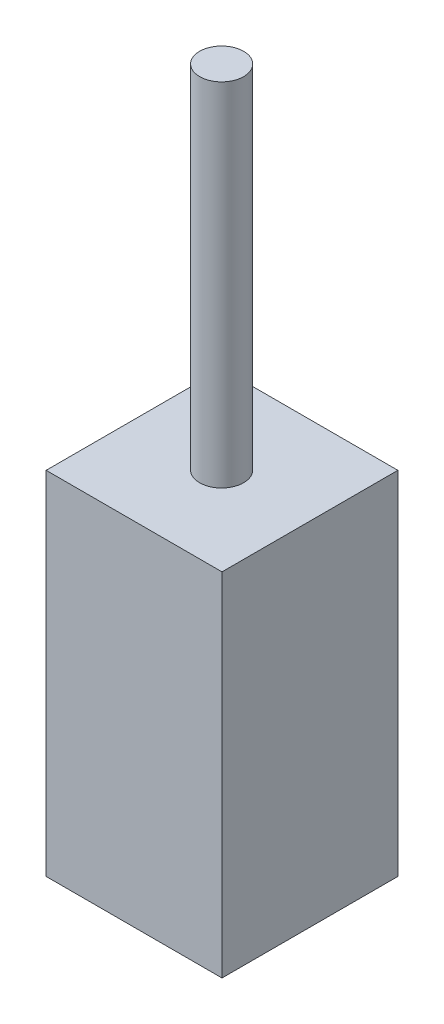
from build123d import *

# Parameters (mm, degrees)
SKETCH1_W           = 25.4
SKETCH1_H           = 25.4
BOSS_EXTRUDE1_DEPTH = 50.8
SKETCH2_R           = 3.175
BOSS_EXTRUDE2_DEPTH = 50.8
CUT_EXTRUDE1_DEPTH  = 1.27


with BuildPart() as part:
    # Sketch1 → Boss-Extrude1 (new body)
    with BuildSketch(Plane(origin=(0, 0, 0), x_dir=(1, 0, 0), z_dir=(0, 1, 0))):
        with Locations((12.7, 12.7)):
            Rectangle(SKETCH1_W, SKETCH1_H)
    extrude(amount=BOSS_EXTRUDE1_DEPTH)

    # Sketch2 → Boss-Extrude2 (add)
    with BuildSketch(Plane(origin=(0, 50.8, 0), x_dir=(1, 0, 0), z_dir=(0, 1, 0))):
        with Locations((12.648058093, 12.7)):
            Circle(SKETCH2_R)
    extrude(amount=BOSS_EXTRUDE2_DEPTH)

    # Sketch3 → Cut-Extrude1 (cut)
    with BuildSketch(Plane.ZY):
        Polygon((-20.429638912, 24.416659376), (-20.010503295, 27.591659376), (-19.969798167, 27.591659376), (-18.658965835, 24.986531171), (-17.351313592, 27.591659376), (-17.309972446, 27.591659376), (-16.888292758, 24.416659376), (-17.174500691, 24.416659376), (-17.478517117, 26.701234697), (-18.624620883, 24.416659376), (-18.688858664, 24.416659376), (-19.839414553, 26.706322838), (-20.142794962, 24.416659376), align=None)
        Polygon((-16.237010707, 27.591659376), (-14.445985066, 27.591659376), (-14.445985066, 27.26601835), (-15.95207481, 27.26601835), (-15.95207481, 26.289095273), (-14.445985066, 26.289095273), (-14.445985066, 25.963454248), (-15.95207481, 25.963454248), (-15.95207481, 24.742300402), (-14.445985066, 24.742300402), (-14.445985066, 24.416659376), (-16.237010707, 24.416659376), align=None)
        with BuildLine():
            add(Edge.make_bspline(
                [(-12.390376092, 27.673069632), (-12.331585881, 27.671580576), (-12.216117058, 27.668655947), (-12.046413401, 27.646268474), (-11.884402136, 27.607537656), (-11.72876351, 27.555954808), (-11.581359167, 27.487144044), (-11.4410796, 27.403972516), (-11.308258579, 27.305568872), (-11.184686325, 27.192693787), (-11.071604663, 27.069881654), (-10.971976895, 26.93881955), (-10.888481386, 26.800299922), (-10.819914279, 26.654739026), (-10.766121969, 26.502466055), (-10.72900255, 26.34266921), (-10.705291514, 26.176383855), (-10.702519488, 26.062966628), (-10.701113271, 26.005431411)],
                knots=[0, 0, 0, 0, 0.000176342, 0.00034635, 0.000512345, 0.00067546, 0.000837376, 0.000999356, 0.00116396, 0.001332355, 0.001500709, 0.001664166, 0.001825381, 0.001984993, 0.002146116, 0.00230887, 0.002476442, 0.002648971, 0.002648971, 0.002648971, 0.002648971], degree=3))
            add(Edge.make_bspline(
                [(-10.701113271, 26.005431411), (-10.702519281, 25.948320013), (-10.70529069, 25.835746832), (-10.72902951, 25.670516708), (-10.76625956, 25.511684433), (-10.819414744, 25.359515162), (-10.887655, 25.213848372), (-10.971706477, 25.07506735), (-11.070713146, 24.943126598), (-11.183386504, 24.819471537), (-11.306214592, 24.706080975), (-11.437959191, 24.607275994), (-11.575657417, 24.522254824), (-11.721081224, 24.454415349), (-11.872301972, 24.400193678), (-12.030673079, 24.363225221), (-12.195452453, 24.339379117), (-12.307821149, 24.336640892), (-12.364935387, 24.33524912)],
                knots=[0, 0, 0, 0, 0.000171259, 0.000337571, 0.000499706, 0.000660019, 0.000820206, 0.000981421, 0.001145895, 0.001314289, 0.001482643, 0.001646609, 0.00180761, 0.001967222, 0.002127146, 0.002288662, 0.002454344, 0.002625603, 0.002625603, 0.002625603, 0.002625603], degree=3))
            add(Edge.make_bspline(
                [(-12.364935387, 24.33524912), (-12.422470305, 24.336654635), (-12.535886943, 24.339425279), (-12.702381254, 24.363175554), (-12.86229035, 24.400315165), (-13.01515694, 24.453391582), (-13.161066269, 24.521987213), (-13.300303701, 24.605629757), (-13.432310356, 24.704877663), (-13.555991798, 24.817514485), (-13.669157142, 24.940134393), (-13.767817433, 25.071519753), (-13.851478785, 25.209092917), (-13.919844094, 25.353235671), (-13.973968282, 25.503251194), (-14.010893367, 25.66014017), (-14.034783838, 25.82300815), (-14.037536877, 25.933899922), (-14.038933784, 25.990166988)],
                knots=[0, 0, 0, 0, 0.00017253, 0.000340102, 0.000503474, 0.000664388, 0.000824575, 0.000986335, 0.001150809, 0.001319204, 0.001487557, 0.001650632, 0.001811303, 0.001969765, 0.00212849, 0.002288769, 0.002452562, 0.00262128, 0.00262128, 0.00262128, 0.00262128], degree=3))
            add(Edge.make_bspline(
                [(-14.038933784, 25.990166988), (-14.038448793, 26.027933767), (-14.03748493, 26.102990879), (-14.025881038, 26.214448437), (-14.009042923, 26.324113534), (-13.984911188, 26.431674323), (-13.953350176, 26.536867502), (-13.916110122, 26.640418551), (-13.87062612, 26.741278072), (-13.819208675, 26.839923863), (-13.761821178, 26.934818177), (-13.698433891, 27.024516085), (-13.631273235, 27.109770275), (-13.557646442, 27.188371485), (-13.479980095, 27.262606302), (-13.397014281, 27.33133391), (-13.309255245, 27.395174044), (-13.216325372, 27.452705353), (-13.120514508, 27.504738282), (-13.021747717, 27.549389533), (-12.921366399, 27.587712746), (-12.818900396, 27.618774066), (-12.71462181, 27.643295984), (-12.608303049, 27.659994084), (-12.500028812, 27.671627572), (-12.427084258, 27.672586878), (-12.390376092, 27.673069632)],
                knots=[0, 0, 0, 0, 0.000113256, 0.000225083, 0.000335817, 0.000445988, 0.000555461, 0.000665116, 0.000775867, 0.0008871, 0.000998686, 0.001108262, 0.001216432, 0.001323994, 0.001431064, 0.001538557, 0.001646949, 0.001756368, 0.001866213, 0.001973803, 0.002081296, 0.002188332, 0.002294783, 0.002402377, 0.00251104, 0.002621117, 0.002621117, 0.002621117, 0.002621117], degree=3))
        make_face()
        with BuildLine():
            add(Edge.make_bspline(
                [(-12.376383704, 27.347428607), (-12.406514122, 27.347061313), (-12.466486908, 27.346330238), (-12.555645023, 27.336700268), (-12.643630563, 27.322975297), (-12.730461698, 27.303397775), (-12.815775118, 27.276724098), (-12.900366045, 27.24602556), (-12.983463101, 27.208632142), (-13.064791958, 27.166384046), (-13.143636348, 27.119621811), (-13.218033584, 27.067940279), (-13.288176268, 27.012551448), (-13.35389266, 26.953326052), (-13.414989795, 26.889962485), (-13.472670203, 26.823421347), (-13.524621895, 26.751800703), (-13.572233811, 26.677042691), (-13.614840352, 26.599244685), (-13.652727495, 26.519225738), (-13.683719131, 26.436333123), (-13.708994287, 26.351466137), (-13.729949115, 26.264759191), (-13.743224175, 26.175554528), (-13.752959958, 26.084300391), (-13.753649247, 26.022631138), (-13.753997887, 25.991439023)],
                knots=[0, 0, 0, 0, 9.035e-05, 0.000179837, 0.000268716, 0.000357433, 0.000446559, 0.000536708, 0.000627246, 0.000719699, 0.000811541, 0.000902048, 0.000991247, 0.001079509, 0.001167217, 0.001255174, 0.001343459, 0.001432386, 0.001520911, 0.0016094, 0.001697761, 0.001786094, 0.001874954, 0.00196509, 0.002056475, 0.002150004, 0.002150004, 0.002150004, 0.002150004], degree=3))
            add(Edge.make_bspline(
                [(-13.753997887, 25.991439023), (-13.752841405, 25.945571866), (-13.750566247, 25.855336978), (-13.730647594, 25.723104447), (-13.699966232, 25.596024359), (-13.654738478, 25.474792056), (-13.598177563, 25.358365456), (-13.52830317, 25.24777739), (-13.445518142, 25.142997968), (-13.351480514, 25.044758688), (-13.248680631, 24.955091423), (-13.139521654, 24.876384617), (-13.025173024, 24.809791033), (-12.905336548, 24.755539289), (-12.780651994, 24.712550026), (-12.65031593, 24.683087268), (-12.515196585, 24.663696677), (-12.423093776, 24.661834534), (-12.376383704, 24.660890145)],
                knots=[0, 0, 0, 0, 0.000137527, 0.000270558, 0.000400289, 0.000529072, 0.000657927, 0.000787976, 0.000920685, 0.001057889, 0.001195382, 0.001329354, 0.001461022, 0.001591668, 0.001723409, 0.001855936, 0.001992028, 0.002132069, 0.002132069, 0.002132069, 0.002132069], degree=3))
            add(Edge.make_bspline(
                [(-12.376383704, 24.660890145), (-12.344987942, 24.661321496), (-12.282720716, 24.662176993), (-12.190105492, 24.67079365), (-12.099158786, 24.684611131), (-12.01000816, 24.704505369), (-11.922754796, 24.729403906), (-11.83703451, 24.758983774), (-11.753760347, 24.795887437), (-11.67188178, 24.83666165), (-11.593508046, 24.883143793), (-11.518690956, 24.933071258), (-11.449316317, 24.988378506), (-11.383649088, 25.046723951), (-11.322301113, 25.109284013), (-11.265687249, 25.175977357), (-11.213998129, 25.247224953), (-11.166404292, 25.321869571), (-11.123947047, 25.399880457), (-11.086954578, 25.480189522), (-11.055570959, 25.562599014), (-11.030235815, 25.647227797), (-11.010382575, 25.733915138), (-10.996702934, 25.822777109), (-10.987133993, 25.913635941), (-10.986412744, 25.975089297), (-10.986049169, 26.006067429)],
                knots=[0, 0, 0, 0, 9.4165e-05, 0.000186757, 0.000278778, 0.000369977, 0.000460573, 0.00055089, 0.000641754, 0.000733627, 0.000825145, 0.000914934, 0.00100324, 0.001091077, 0.00117833, 0.001265874, 0.00135327, 0.001442197, 0.00153128, 0.001619501, 0.001707267, 0.0017956, 0.001884317, 0.001973824, 0.00206521, 0.002158103, 0.002158103, 0.002158103, 0.002158103], degree=3))
            add(Edge.make_bspline(
                [(-10.986049169, 26.006067429), (-10.986413035, 26.036833636), (-10.987134832, 26.097864076), (-10.996698363, 26.188089247), (-11.010397028, 26.276311803), (-11.030138913, 26.362185396), (-11.055584409, 26.445731915), (-11.086960059, 26.526872893), (-11.123958152, 26.605910613), (-11.166419899, 26.682649725), (-11.214149967, 26.756286809), (-11.266305459, 26.826683283), (-11.323786882, 26.892517127), (-11.384951919, 26.9554136), (-11.451328365, 27.014031257), (-11.522615546, 27.068389543), (-11.597948025, 27.119800299), (-11.677710589, 27.166178488), (-11.760028318, 27.209008542), (-11.84449598, 27.24570338), (-11.930156663, 27.276883803), (-12.016792537, 27.303478478), (-12.10513281, 27.32289862), (-12.194580569, 27.336712636), (-12.28501206, 27.346326886), (-12.345829838, 27.347060201), (-12.376383704, 27.347428607)],
                knots=[0, 0, 0, 0, 9.2258e-05, 0.00018301, 0.000271889, 0.000359986, 0.000447102, 0.00053368, 0.000620747, 0.000708715, 0.000796571, 0.000883833, 0.000971308, 0.00105856, 0.001146873, 0.001236684, 0.001327357, 0.001420293, 0.001513311, 0.001605595, 0.001696341, 0.001786684, 0.001877263, 0.001967398, 0.00205815, 0.002149772, 0.002149772, 0.002149772, 0.002149772], degree=3))
        make_face(mode=Mode.SUBTRACT)
        Polygon((-10.253356861, 27.591659376), (-9.958880699, 27.591659376), (-9.337491476, 25.263198839), (-8.413357863, 27.591659376), (-8.372016717, 27.591659376), (-7.465055579, 25.27909928), (-6.840486268, 27.591659376), (-6.549190194, 27.591659376), (-7.405269922, 24.416659376), (-7.44597505, 24.416659376), (-8.401273528, 26.84497468), (-9.368020323, 24.416659376), (-9.408725451, 24.416659376), align=None)
    extrude(amount=-CUT_EXTRUDE1_DEPTH, mode=Mode.SUBTRACT)


solid = part.part
